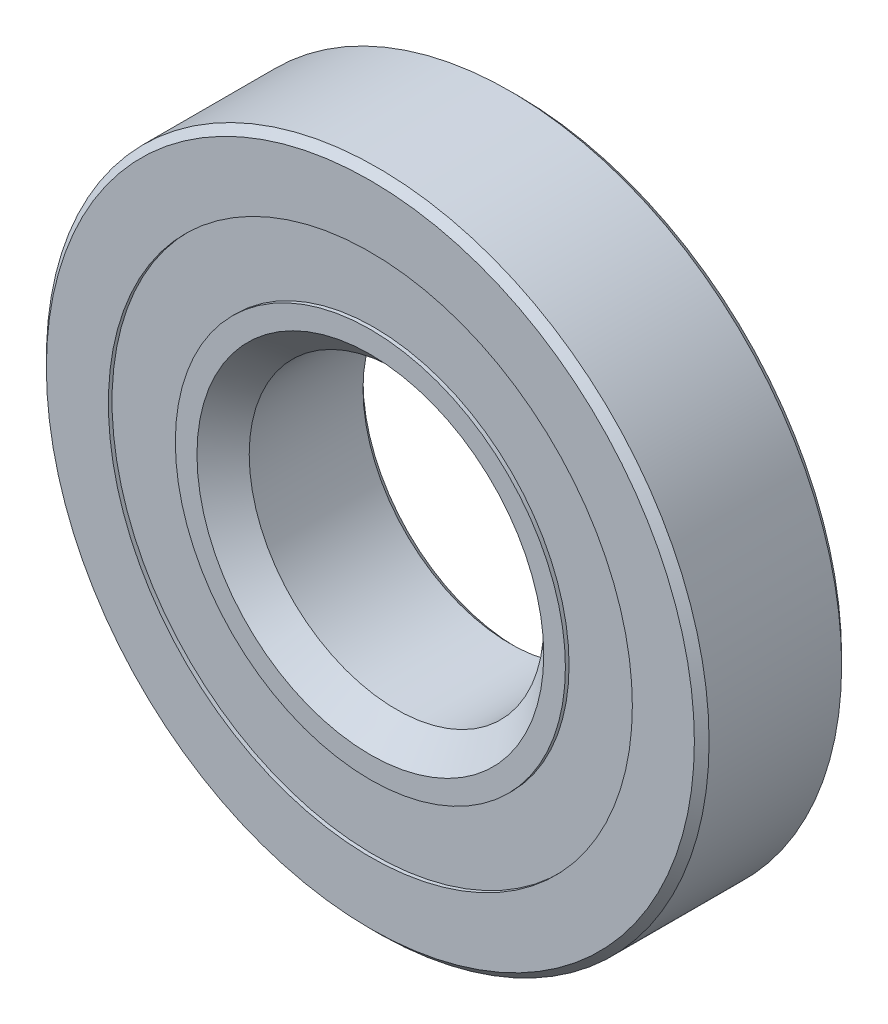
from build123d import *

# Parameters (mm, degrees)
CIRPATTERN1_COUNT = 12
SKETCH5_W         = 1.299971099
SKETCH5_H         = 2.886641841


with BuildPart() as part:
    # Sketch1 → Revolve1 (revolve)
    with BuildSketch(Plane(origin=(0, 0, 0), x_dir=(0, 0, -1), z_dir=(1, 0, 0))):
        with BuildLine():
            Line((2.8575, 14.2875), (-2.8575, 14.2875))
            Line((-2.8575, 14.2875), (-3.175, 13.97))
            Line((-3.175, 13.97), (-3.175, 11.295673077))
            Line((-3.175, 11.295673077), (-1.411111111, 11.295673077))
            ThreePointArc((-1.411111111, 11.295673077), (0, 12.035028901), (1.411111111, 11.295673077))
            Line((1.411111111, 11.295673077), (3.175, 11.295673077))
            Line((3.175, 11.295673077), (3.175, 13.97))
            Line((3.175, 13.97), (2.8575, 14.2875))
        make_face()
    revolve(axis=Axis((0, 0, 3.175), (0, 0, -1)))


with BuildPart() as body_2:
    # Sketch3 → Revolve3 (revolve)
    with BuildSketch(Plane(origin=(0, 0, 0), x_dir=(0, 0, -1), z_dir=(1, 0, 0))):
        with BuildLine():
            Line((-3.01625, 8.250281236), (-2.242204313, 7.476235549))
            Line((-2.242204313, 7.476235549), (0, 7.476235549))
            Line((0, 7.476235549), (0, 8.602471099))
            ThreePointArc((0, 8.602471099), (0.796536503, 8.798505656), (1.411111111, 9.341826923))
            Line((1.411111111, 9.341826923), (3.175, 9.341826923))
            Line((3.175, 9.341826923), (3.175, 6.6675))
            Line((3.175, 6.6675), (2.8575, 6.35))
            Line((2.8575, 6.35), (-2.048764451, 6.35))
            Line((-2.048764451, 6.35), (-3.175, 7.476235549))
            Line((-3.175, 7.476235549), (-3.175, 8.409031236))
            Line((-3.175, 8.409031236), (-3.01625, 8.409031236))
            Line((-3.01625, 8.409031236), (-3.01625, 8.250281236))
        make_face()
    revolve(axis=Axis((0, 0, 3.175), (0, 0, -1)))


with BuildPart() as body_3:
    # Sketch4 → Revolve4 (revolve)
    with BuildSketch(Plane(origin=(0, 0, 0), x_dir=(0, 0, -1), z_dir=(1, 0, 0))):
        with BuildLine():
            Line((-1.716278901, 10.31875), (1.716278901, 10.31875))
            ThreePointArc((1.716278901, 10.31875), (0, 12.035028901), (-1.716278901, 10.31875))
        make_face()
    revolve(axis=Axis((0, 10.31875, 1.716278901), (0, 0, -1)))


with BuildPart() as cirpattern1_1:
    # CirPattern1: pattern copy
    add(body_3.part.rotate(Axis((0, 0, -3.175), (0, 0, 1)), 1 * 360 / CIRPATTERN1_COUNT))


with BuildPart() as cirpattern1_2:
    # CirPattern1: pattern copy
    add(body_3.part.rotate(Axis((0, 0, -3.175), (0, 0, 1)), 2 * 360 / CIRPATTERN1_COUNT))


with BuildPart() as cirpattern1_3:
    # CirPattern1: pattern copy
    add(body_3.part.rotate(Axis((0, 0, -3.175), (0, 0, 1)), 3 * 360 / CIRPATTERN1_COUNT))


with BuildPart() as cirpattern1_4:
    # CirPattern1: pattern copy
    add(body_3.part.rotate(Axis((0, 0, -3.175), (0, 0, 1)), 4 * 360 / CIRPATTERN1_COUNT))


with BuildPart() as cirpattern1_5:
    # CirPattern1: pattern copy
    add(body_3.part.rotate(Axis((0, 0, -3.175), (0, 0, 1)), 5 * 360 / CIRPATTERN1_COUNT))


with BuildPart() as cirpattern1_6:
    # CirPattern1: pattern copy
    add(body_3.part.rotate(Axis((0, 0, -3.175), (0, 0, 1)), 6 * 360 / CIRPATTERN1_COUNT))


with BuildPart() as cirpattern1_7:
    # CirPattern1: pattern copy
    add(body_3.part.rotate(Axis((0, 0, -3.175), (0, 0, 1)), 7 * 360 / CIRPATTERN1_COUNT))


with BuildPart() as cirpattern1_8:
    # CirPattern1: pattern copy
    add(body_3.part.rotate(Axis((0, 0, -3.175), (0, 0, 1)), 8 * 360 / CIRPATTERN1_COUNT))


with BuildPart() as cirpattern1_9:
    # CirPattern1: pattern copy
    add(body_3.part.rotate(Axis((0, 0, -3.175), (0, 0, 1)), 9 * 360 / CIRPATTERN1_COUNT))


with BuildPart() as cirpattern1_10:
    # CirPattern1: pattern copy
    add(body_3.part.rotate(Axis((0, 0, -3.175), (0, 0, 1)), 10 * 360 / CIRPATTERN1_COUNT))


with BuildPart() as cirpattern1_11:
    # CirPattern1: pattern copy
    add(body_3.part.rotate(Axis((0, 0, -3.175), (0, 0, 1)), 11 * 360 / CIRPATTERN1_COUNT))


with BuildPart() as body_15:
    # Sketch5 → Revolve5 (revolve)
    with BuildSketch(Plane(origin=(0, 0, 0), x_dir=(0, 0, -1), z_dir=(1, 0, 0))):
        with Locations((-2.366264451, 9.852352157)):
            Rectangle(SKETCH5_W, SKETCH5_H)
        with Locations((2.366264451, 9.852352157)):
            Rectangle(SKETCH5_W, SKETCH5_H)
    revolve(axis=Axis((0, 0, 3.175), (0, 0, -1)))


solid = Compound([part.part, body_2.part, body_3.part, cirpattern1_1.part, cirpattern1_2.part, cirpattern1_3.part, cirpattern1_4.part, cirpattern1_5.part, cirpattern1_6.part, cirpattern1_7.part, cirpattern1_8.part, cirpattern1_9.part, cirpattern1_10.part, cirpattern1_11.part, body_15.part])
